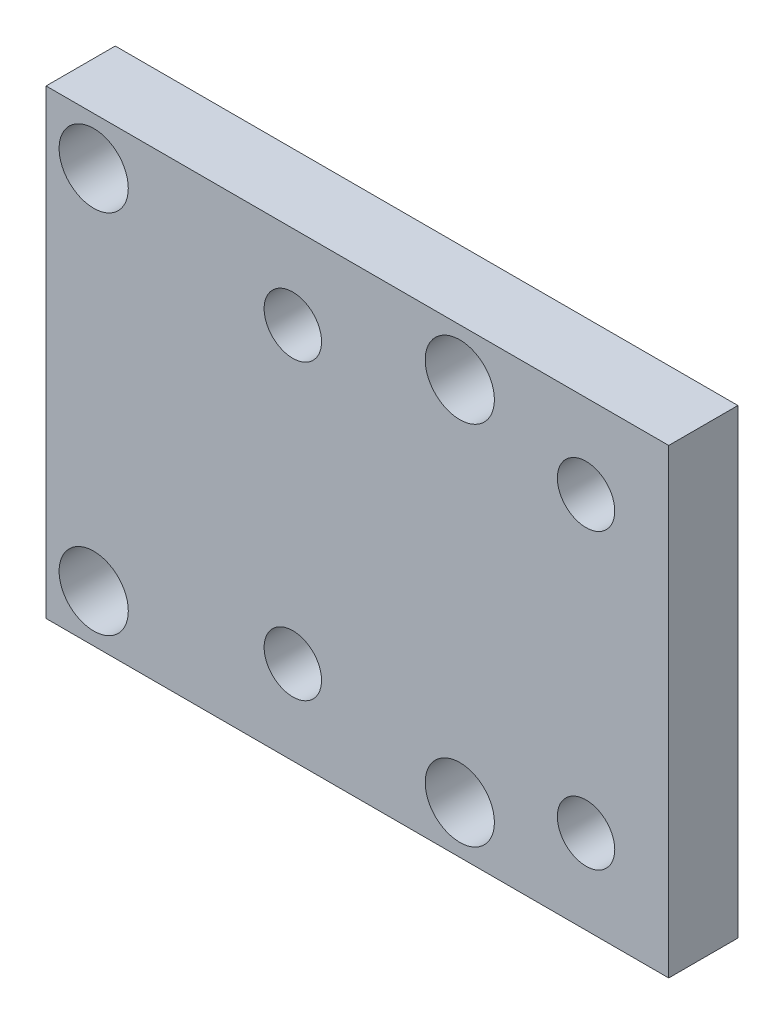
from build123d import *

# Parameters (mm, degrees)
SKETCH1_W           = 54
SKETCH1_H           = 40
BOSS_EXTRUDE1_DEPTH = 6
SKETCH2_R           = 2
CUT_EXTRUDE2_DEPTH  = 7
SKETCH8_R           = 3
CUT_EXTRUDE6_DEPTH  = 5
SKETCH9_R           = 2.49
CUT_EXTRUDE7_DEPTH  = 6


with BuildPart() as part:
    # Sketch1 → Boss-Extrude1 (new body)
    with BuildSketch(Plane.XY):
        with Locations((-38.43, -20)):
            Rectangle(SKETCH1_W, SKETCH1_H)
    extrude(amount=BOSS_EXTRUDE1_DEPTH)

    # Sketch2 → Cut-Extrude2 (cut, through all)
    with BuildSketch(Plane.XY):
        with Locations((-61.3, -35.875)):
            Circle(SKETCH2_R)
        with Locations((-29.55, -35.875)):
            Circle(SKETCH2_R)
        with Locations((-29.55, -4.125)):
            Circle(SKETCH2_R)
        with Locations((-61.3, -4.125)):
            Circle(SKETCH2_R)
    extrude(amount=CUT_EXTRUDE2_DEPTH, mode=Mode.SUBTRACT)

    # Sketch8 → Cut-Extrude6 (cut)
    with BuildSketch(Plane.XY.offset(6)):
        with Locations((-61.3, -4.125)):
            Circle(SKETCH8_R)
        with Locations((-29.55, -4.125)):
            Circle(SKETCH8_R)
        with Locations((-29.55, -35.875)):
            Circle(SKETCH8_R)
        with Locations((-61.3, -35.875)):
            Circle(SKETCH8_R)
    extrude(amount=-CUT_EXTRUDE6_DEPTH, mode=Mode.SUBTRACT)

    # Sketch9 → Cut-Extrude7 (cut)
    with BuildSketch(Plane.XY.offset(6)):
        with Locations((-44.030806884, -7.27)):
            Circle(SKETCH9_R)
        with Locations((-18.600806884, -7.27)):
            Circle(SKETCH9_R)
        with Locations((-44.030806884, -32.7)):
            Circle(SKETCH9_R)
        with Locations((-18.600806884, -32.7)):
            Circle(SKETCH9_R)
    extrude(amount=-CUT_EXTRUDE7_DEPTH, mode=Mode.SUBTRACT)


solid = part.part
